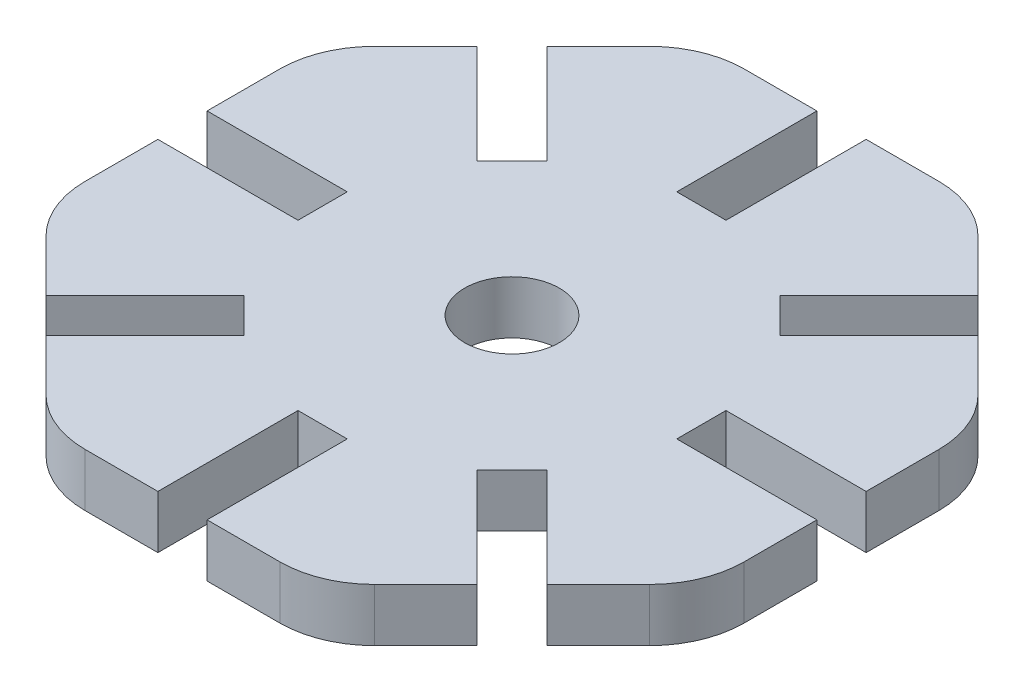
from build123d import *

# Parameters (mm, degrees)
SKETCH1_R           = 2.5
BOSS_EXTRUDE1_DEPTH = 2.8


with BuildPart() as part:
    # Sketch1 → Boss-Extrude1 (new body)
    with BuildSketch(Plane(origin=(0, 0, 0), x_dir=(1, 0, 0), z_dir=(0, 1, 0))):
        with BuildLine():
            Line((-1.3, -17.4), (-1.3, -10))
            Line((-1.3, -10), (1.3, -10))
            Line((1.3, -10), (1.3, -17.4))
            Line((1.3, -17.4), (5.136248173, -17.4))
            ThreePointArc((5.136248173, -17.4), (7.049665335, -17.019397663), (8.671782079, -15.935533906))
            Line((8.671782079, -15.935533906), (11.384419177, -13.222896808))
            Line((11.384419177, -13.222896808), (6.151828996, -7.990306627))
            Line((6.151828996, -7.990306627), (7.990306627, -6.151828996))
            Line((7.990306627, -6.151828996), (13.222896808, -11.384419177))
            Line((13.222896808, -11.384419177), (15.935533906, -8.671782079))
            ThreePointArc((15.935533906, -8.671782079), (17.019397663, -7.049665335), (17.4, -5.136248173))
            Line((17.4, -5.136248173), (17.4, -1.3))
            Line((17.4, -1.3), (10, -1.3))
            Line((10, -1.3), (10, 1.3))
            Line((10, 1.3), (17.4, 1.3))
            Line((17.4, 1.3), (17.4, 5.136248173))
            ThreePointArc((17.4, 5.136248173), (17.019397663, 7.049665335), (15.935533906, 8.671782079))
            Line((15.935533906, 8.671782079), (13.222896808, 11.384419177))
            Line((13.222896808, 11.384419177), (7.990306627, 6.151828996))
            Line((7.990306627, 6.151828996), (6.151828996, 7.990306627))
            Line((6.151828996, 7.990306627), (11.384419177, 13.222896808))
            Line((11.384419177, 13.222896808), (8.671782079, 15.935533906))
            ThreePointArc((8.671782079, 15.935533906), (7.049665335, 17.019397663), (5.136248173, 17.4))
            Line((5.136248173, 17.4), (1.3, 17.4))
            Line((1.3, 17.4), (1.3, 10))
            Line((1.3, 10), (-1.3, 10))
            Line((-1.3, 10), (-1.3, 17.4))
            Line((-1.3, 17.4), (-5.136248173, 17.4))
            ThreePointArc((-5.136248173, 17.4), (-7.049665335, 17.019397663), (-8.671782079, 15.935533906))
            Line((-8.671782079, 15.935533906), (-11.384419177, 13.222896808))
            Line((-11.384419177, 13.222896808), (-6.151828996, 7.990306627))
            Line((-6.151828996, 7.990306627), (-7.990306627, 6.151828996))
            Line((-7.990306627, 6.151828996), (-13.222896808, 11.384419177))
            Line((-13.222896808, 11.384419177), (-15.935533906, 8.671782079))
            ThreePointArc((-15.935533906, 8.671782079), (-17.019397663, 7.049665335), (-17.4, 5.136248173))
            Line((-17.4, 5.136248173), (-17.4, 1.3))
            Line((-17.4, 1.3), (-10, 1.3))
            Line((-10, 1.3), (-10, -1.3))
            Line((-10, -1.3), (-17.4, -1.3))
            Line((-17.4, -1.3), (-17.4, -5.136248173))
            ThreePointArc((-17.4, -5.136248173), (-17.019397663, -7.049665335), (-15.935533906, -8.671782079))
            Line((-15.935533906, -8.671782079), (-13.222896808, -11.384419177))
            Line((-13.222896808, -11.384419177), (-7.990306627, -6.151828996))
            Line((-7.990306627, -6.151828996), (-6.151828996, -7.990306627))
            Line((-6.151828996, -7.990306627), (-11.384419177, -13.222896808))
            Line((-11.384419177, -13.222896808), (-8.671782079, -15.935533906))
            ThreePointArc((-8.671782079, -15.935533906), (-7.049665335, -17.019397663), (-5.136248173, -17.4))
            Line((-5.136248173, -17.4), (-1.3, -17.4))
        make_face()
        with Locations(Location((0, 0, 0), (0, 0, 270))):  # turned: the seam where the file's is
            Circle(SKETCH1_R, mode=Mode.SUBTRACT)
    extrude(amount=BOSS_EXTRUDE1_DEPTH)


solid = part.part
